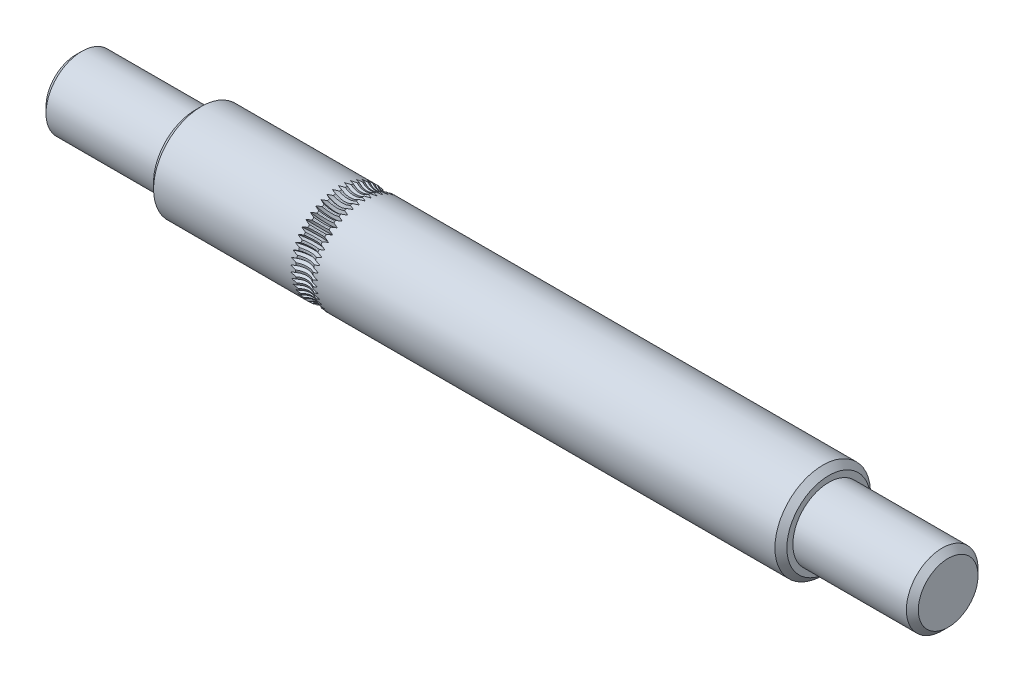
from build123d import *

# Parameters (mm, degrees)
CHAMFER1_SIZE     = 0.5
CIRPATTERN1_COUNT = 50


with BuildPart() as part:
    # Sketch1 → Revolve1 (revolve)
    with BuildSketch(Plane.XY):
        Polygon((-13.1, 4), (39.9, 4), (39.9, 3), (49.9, 3), (49.9, 0), (-23.1, 0), (-23.1, 3), (-13.1, 3), align=None)
    revolve(axis=Axis((0, 0, 0), (1, 0, 0)))

    # Chamfer1
    chamfer1_edges = [part.edges().sort_by_distance(p)[0] for p in [
        (-23.1, -3, 0),
        (49.9, -3, 0),
        (39.9, -4, 0),
        (-13.1, -4, 0),
    ]]
    chamfer(chamfer1_edges, length=CHAMFER1_SIZE)

    # Sketch2 → Cut-Revolve1 (revolve, cut)
    with BuildSketch(Plane(origin=(0, 0, 0), x_dir=(0, 0, -1), z_dir=(1, 0, 0))):
        Polygon((0.156173248, 3.7705), (0, 3.5), (-0.156173248, 3.7705), (-1.3354137, 3.7705), (-1.3354137, 5), (1.3354137, 5), (1.3354137, 3.7705), align=None)
    cut_revolve1 = revolve(axis=Axis((0, 5, -9.989903303), (0, 0, 1)), mode=Mode.SUBTRACT)

    # CirPattern1: Cut-Revolve1 ×50 about axis
    cirpattern1_axis = Axis((0, 0, 0), (-1, 0, 0))
    for i in range(1, CIRPATTERN1_COUNT):
        add(cut_revolve1.rotate(cirpattern1_axis, i * 360 / CIRPATTERN1_COUNT), mode=Mode.SUBTRACT)


solid = part.part
